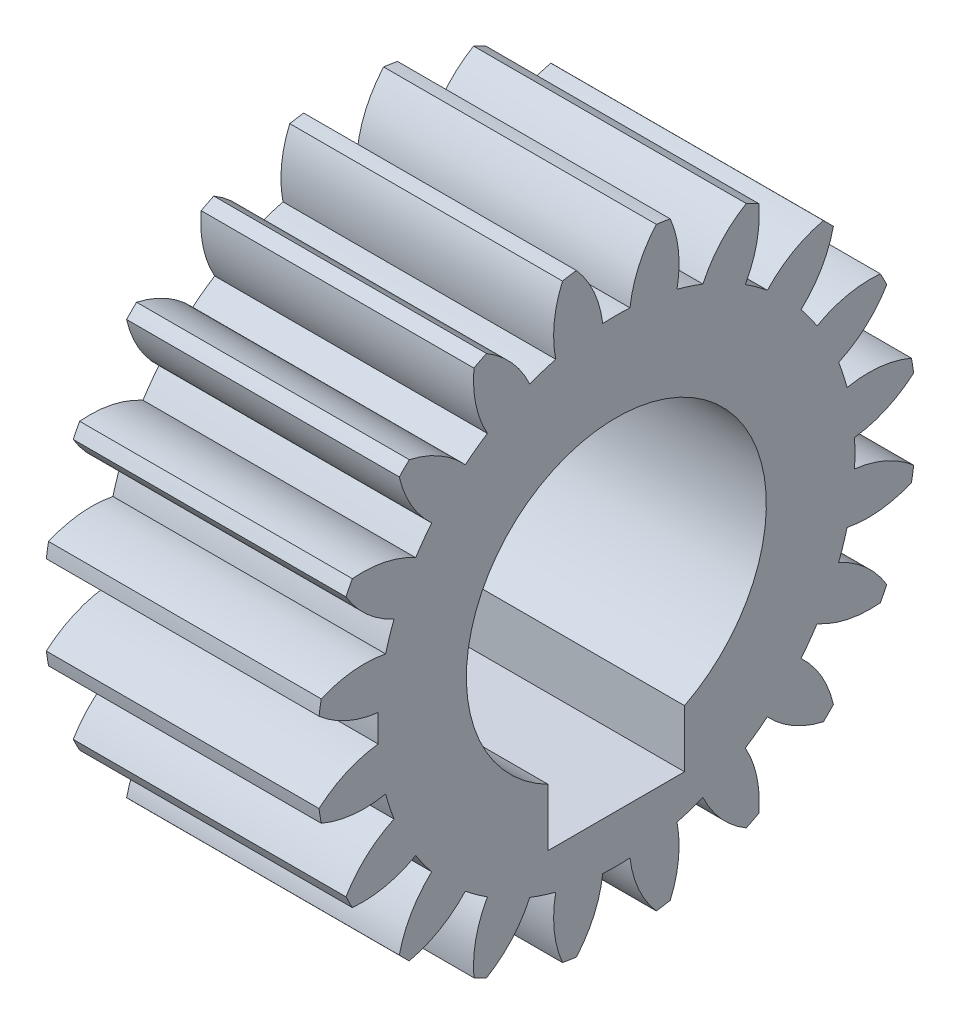
from build123d import *

# Parameters (mm, degrees)
BASPROSKE_W             = 5
BASPROSKE_H             = 5.5
TOOTHCUT_DEPTH          = 10.246621004
TEETHCUTS_COUNT         = 20
TEETHCUTS_ANGLE         = 342
BORSKE_R                = 0.5
BORE_DEPTH              = 50.0000508
CUT_EXTRUDE1_DEPTH      = 10.188413972
CUT_EXTRUDE1_DEPTH_BACK = 10.188413972


with BuildPart() as part:
    # BasProSke → Base-Revolve (revolve)
    with BuildSketch(Plane(origin=(0, 0, 0), x_dir=(1, 0, 0), z_dir=(0, 1, 0)), mode=Mode.PRIVATE) as base_revolve_sk:
        with Locations((2.5, 2.75)):
            Rectangle(BASPROSKE_W, BASPROSKE_H)
    revolve(base_revolve_sk.sketch.rotate(Axis((-10, 0, 0), (1, 0, 0)), 180), axis=Axis((-10, 0, 0), (1, 0, 0)))

    # TooCutSke → ToothCut (cut, through all)
    with BuildSketch(Plane(origin=(0, 0, 0), x_dir=(0, 0, -1), z_dir=(1, 0, 0))):
        with BuildLine():
            ThreePointArc((0.249903181, 4.366855207), (0, 4.374), (-0.249903181, 4.366855207))
            ThreePointArc((-0.249903181, 4.366855207), (-0.415207844, 4.95951031), (-0.752843848, 5.473871692))
            ThreePointArc((-0.752843848, 5.473871692), (0, 5.5254), (0.752843848, 5.473871692))
            ThreePointArc((0.752843848, 5.473871692), (0.415207844, 4.95951031), (0.249903181, 4.366855207))
        make_face()
    toothcut = extrude(amount=TOOTHCUT_DEPTH, mode=Mode.SUBTRACT)

    # TeethCuts: ToothCut ×20 about axis
    teethcuts_axis = Axis((-10, 0, 0), (1, 0, 0))
    for i in range(1, TEETHCUTS_COUNT):
        add(toothcut.rotate(teethcuts_axis, i * TEETHCUTS_ANGLE / (TEETHCUTS_COUNT - 1)), mode=Mode.SUBTRACT)

    # BorSke → Bore (cut, symmetric)
    with BuildSketch(Plane(origin=(0, 0, 0), x_dir=(0, 0, -1), z_dir=(1, 0, 0))):
        with Locations(Location((0, 0, 0), (0, 0, 180))):
            Circle(BORSKE_R)
    extrude(amount=BORE_DEPTH, both=True, mode=Mode.SUBTRACT)

    # Sketch1 → Cut-Extrude1 (cut, two sides)
    with BuildSketch(Plane(origin=(5, 0, 0), x_dir=(0, 0, -1), z_dir=(1, 0, 0))) as cut_extrude1_sk:
        with BuildLine():
            Line((1.25, -1.759357098), (-1.25, -1.759357098))
            Line((-1.25, -1.759357098), (-1.25, -2.449489743))
            ThreePointArc((-1.25, -2.449489743), (0, -2.75), (1.25, -2.449489743))
            Line((1.25, -2.449489743), (1.25, -1.759357098))
        make_face()
        with BuildLine():
            Line((-1.25, -2.449489743), (-1.25, -1.759357098))
            Line((-1.25, -1.759357098), (1.25, -1.759357098))
            Line((1.25, -1.759357098), (1.25, -2.449489743))
            ThreePointArc((1.25, -2.449489743), (2.34520788, -1.436140662), (2.75, 0))
            ThreePointArc((2.75, 0), (-1.436140662, 2.34520788), (-1.25, -2.449489743))
        make_face()
        with BuildLine():
            ThreePointArc((1.25, -2.449489743), (0, -2.75), (-1.25, -2.449489743))
            Line((-1.25, -2.449489743), (-1.25, -3.5))
            Line((-1.25, -3.5), (1.25, -3.5))
            Line((1.25, -3.5), (1.25, -2.449489743))
        make_face()
    extrude(amount=CUT_EXTRUDE1_DEPTH, mode=Mode.SUBTRACT)
    extrude(cut_extrude1_sk.sketch, amount=-CUT_EXTRUDE1_DEPTH_BACK, mode=Mode.SUBTRACT)


solid = part.part
